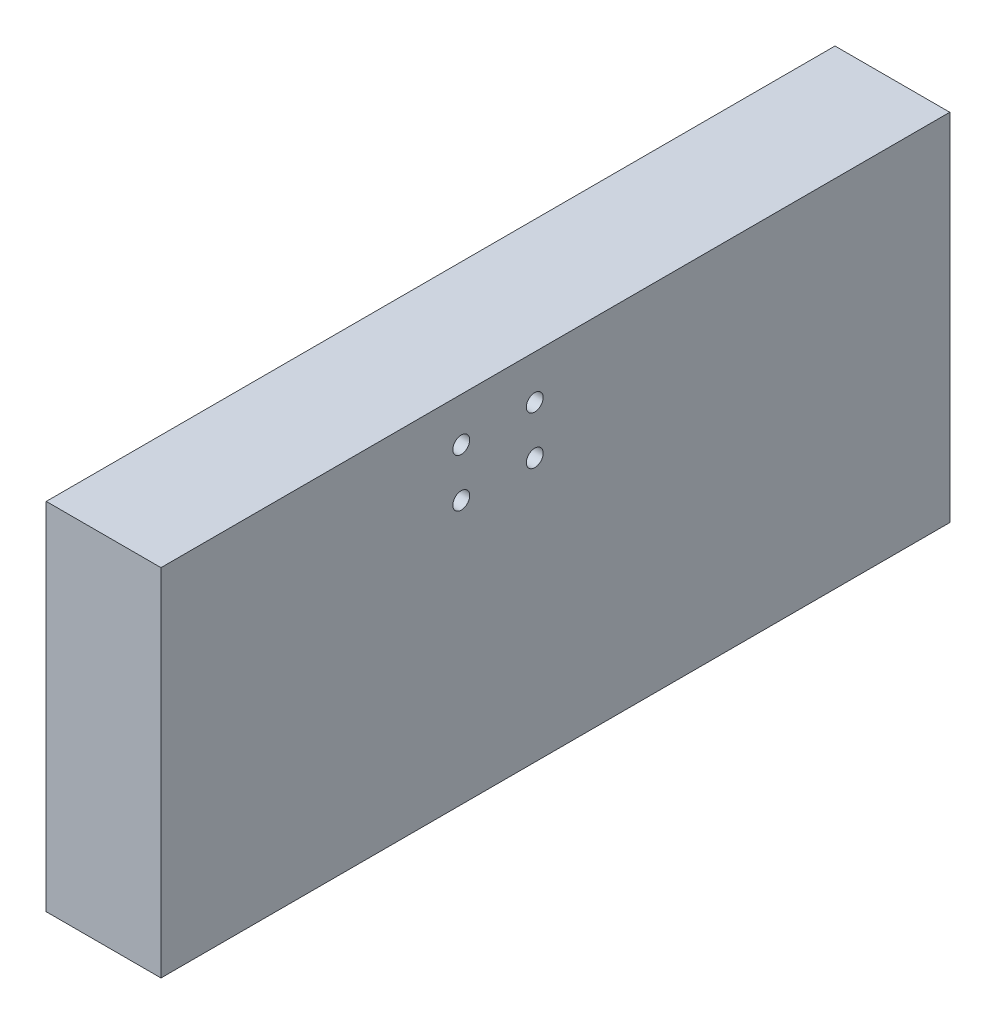
from build123d import *

# Parameters (mm, degrees)
SKETCH1_W           = 150
SKETCH1_H           = 150
BOSS_EXTRUDE1_DEPTH = 59
SKETCH2_W           = 111.9
SKETCH2_H           = 111.9
CUT_EXTRUDE1_DEPTH  = 122.371331047
SKETCH9_R           = 1.4
CUT_EXTRUDE4_DEPTH  = 20
CIRPATTERN1_COUNT   = 3
CIRPATTERN1_ANGLE   = 180
SKETCH10_W          = 111.9
SKETCH10_H          = 105.448295943
CUT_EXTRUDE6_DEPTH  = 122.371331047
CUT_EXTRUDE7_DEPTH  = 122.371331047


with BuildPart() as part:
    # Sketch1 → Boss-Extrude1 (new body)
    with BuildSketch(Plane(origin=(0, 0, 0), x_dir=(1, 0, 0), z_dir=(0, 1, 0))):
        Rectangle(SKETCH1_W, SKETCH1_H)
    extrude(amount=-BOSS_EXTRUDE1_DEPTH)

    # Sketch2 → Cut-Extrude1 (cut, through all)
    with BuildSketch(Plane(origin=(0, 0, 0), x_dir=(1, 0, 0), z_dir=(0, 1, 0))):
        Rectangle(SKETCH2_W, SKETCH2_H)
    extrude(amount=-CUT_EXTRUDE1_DEPTH, mode=Mode.SUBTRACT)

    # Sketch9 → Cut-Extrude4 (cut)
    with BuildSketch(Plane.ZY.offset(75)):
        with Locations((-6.1, -7.25)):
            Circle(SKETCH9_R)
        with Locations((6.1, -7.25)):
            Circle(SKETCH9_R)
        with Locations((6.1, -15.25)):
            Circle(SKETCH9_R)
        with Locations((-6.1, -15.25)):
            Circle(SKETCH9_R)
    cut_extrude4 = extrude(amount=-CUT_EXTRUDE4_DEPTH, mode=Mode.SUBTRACT)

    # CirPattern1: Cut-Extrude4 ×3 about axis
    cirpattern1_axis = Axis((0, 0, 0), (0, 1, 0))
    for i in range(1, CIRPATTERN1_COUNT):
        add(cut_extrude4.rotate(cirpattern1_axis, i * CIRPATTERN1_ANGLE / (CIRPATTERN1_COUNT - 1)), mode=Mode.SUBTRACT)

    # Sketch10 → Cut-Extrude6 (cut, through all)
    with BuildSketch(Plane(origin=(0, 0, 0), x_dir=(1, 0, 0), z_dir=(0, 1, 0))):
        with Locations((0, 108.674147972)):
            Rectangle(SKETCH10_W, SKETCH10_H)
    extrude(amount=-CUT_EXTRUDE6_DEPTH, mode=Mode.SUBTRACT)

    # Sketch11 → Cut-Extrude7 (cut, through all)
    with BuildSketch(Plane(origin=(0, 0, 0), x_dir=(1, 0, 0), z_dir=(0, 1, 0))):
        Polygon((-55.95, -55.95), (-75, -55.95), (-75, -75), (75, -75), (75, 75), (-55.95, 75), align=None)
    extrude(amount=-CUT_EXTRUDE7_DEPTH, mode=Mode.SUBTRACT)


solid = part.part
